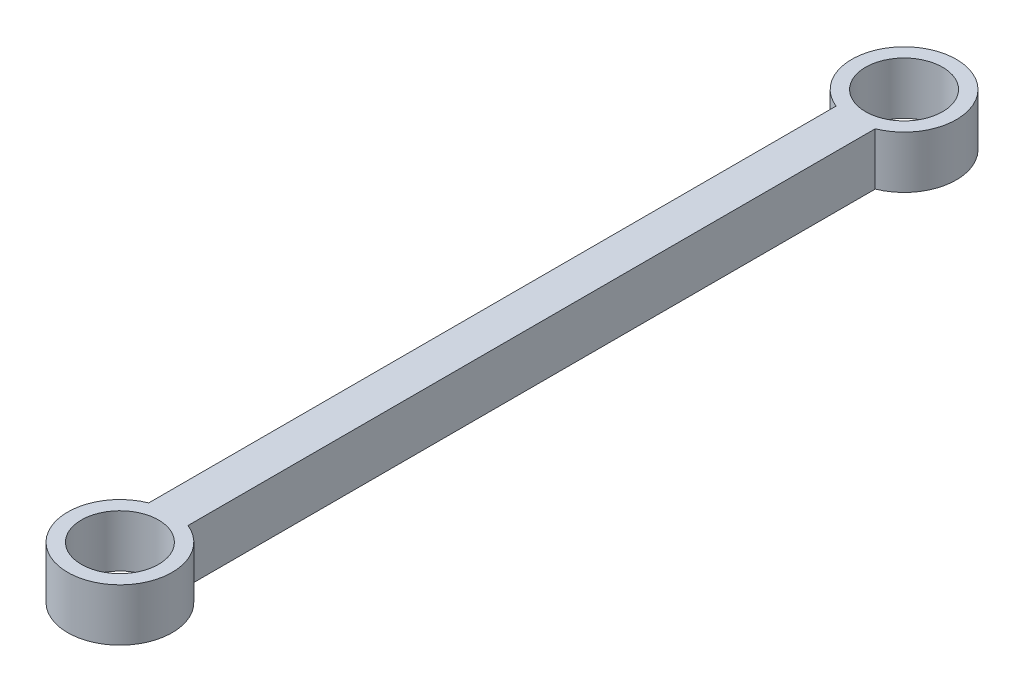
from build123d import *

# Parameters (mm, degrees)
SKETCH1_R           = 2.95
BOSS_EXTRUDE1_DEPTH = 4


with BuildPart() as part:
    # Sketch1 → Boss-Extrude1 (new body)
    with BuildSketch(Plane(origin=(0, 0, 0), x_dir=(1, 0, 0), z_dir=(0, 1, 0))):
        with BuildLine():
            Line((-1.5, 56.291900756), (-1.5, 3.708099244))
            ThreePointArc((-1.5, 3.708099244), (0, -4), (1.5, 3.708099244))
            Line((1.5, 3.708099244), (1.5, 56.291900756))
            ThreePointArc((1.5, 56.291900756), (0, 64), (-1.5, 56.291900756))
        make_face()
        with Locations((0, 60)):
            Circle(SKETCH1_R, mode=Mode.SUBTRACT)
        Circle(SKETCH1_R, mode=Mode.SUBTRACT)
    extrude(amount=BOSS_EXTRUDE1_DEPTH)


solid = part.part
